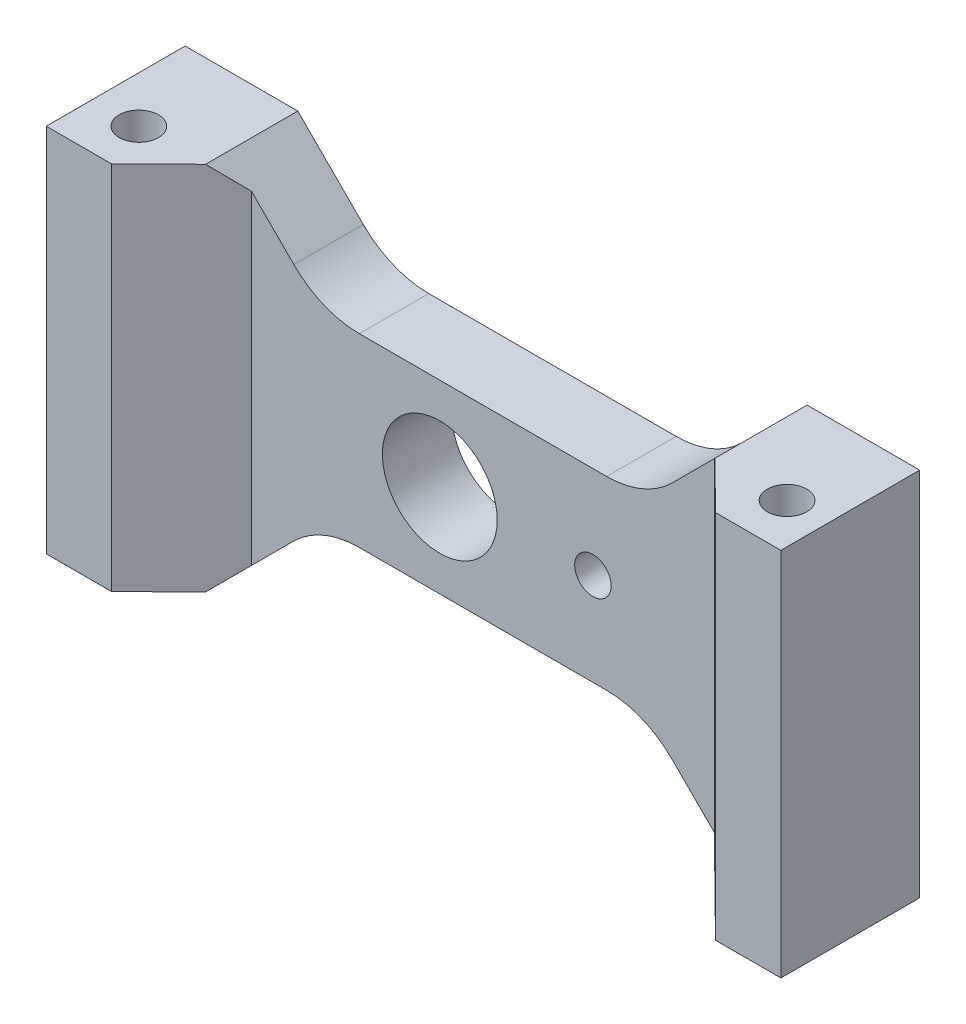
from build123d import *

# Parameters (mm, degrees)
SKETCH1_R                 = 1.35255
BOSS_EXTRUDE1_DEPTH       = 25.4
SKETCH2_R                 = 3.937
CUT_EXTRUDE1_DEPTH        = 5.7625
M3X0_5_TAPPED_HOLE1_D     = 2.5
M3X0_5_TAPPED_HOLE1_DEPTH = 4.7625
CUT_EXTRUDE2_DEPTH        = 10.525


with BuildPart() as part:
    # Sketch1 → Boss-Extrude1 (new body)
    with BuildSketch(Plane(origin=(0, 0, 0), x_dir=(1, 0, 0), z_dir=(0, 1, 0))):
        Polygon((25.187315329, 0), (-25.187315329, 0), (-25.187315329, -9.525), (-20.711502729, -9.525), (-15.875, -4.7625), (15.875, -4.7625), (20.711502729, -9.525), (25.187315329, -9.525), align=None)
        with Locations((-22.012315329, -6.35)):
            Circle(SKETCH1_R, mode=Mode.SUBTRACT)
        with Locations((22.437684671, -6.35)):
            Circle(SKETCH1_R, mode=Mode.SUBTRACT)
    extrude(amount=BOSS_EXTRUDE1_DEPTH)

    # Sketch2 → Cut-Extrude1 (cut, through all)
    with BuildSketch(Plane.XY.offset(4.7625)):
        with Locations((-2.962315329, 12.7)):
            Circle(SKETCH2_R)
    extrude(amount=-CUT_EXTRUDE1_DEPTH, mode=Mode.SUBTRACT)

    # M3x0.5 Tapped Hole1
    with Locations(Plane.XY.offset(4.7625)):
        with Locations((7.537684671, 12.7)):
            Hole(M3X0_5_TAPPED_HOLE1_D / 2, depth=M3X0_5_TAPPED_HOLE1_DEPTH)

    # Sketch6 → Cut-Extrude2 (cut, through all)
    with BuildSketch(Plane(origin=(0, 0, 0), x_dir=(-1, 0, 0), z_dir=(0, 0, -1))):
        with BuildLine():
            Line((-17.4625, 25.4), (-12.972371939, 20.909871939))
            ThreePointArc((-12.972371939, 20.909871939), (-10.912283674, 19.533364969), (-8.482243879, 19.05))
            Line((-8.482243879, 19.05), (8.482243879, 19.05))
            ThreePointArc((8.482243879, 19.05), (10.912283674, 19.533364969), (12.972371939, 20.909871939))
            Line((12.972371939, 20.909871939), (17.4625, 25.4))
            Line((17.4625, 25.4), (-17.4625, 25.4))
        make_face()
        with BuildLine():
            Line((-17.4625, 0), (-12.972371939, 4.490128061))
            ThreePointArc((-12.972371939, 4.490128061), (-10.912283674, 5.866635031), (-8.482243879, 6.35))
            Line((-8.482243879, 6.35), (8.482243879, 6.35))
            ThreePointArc((8.482243879, 6.35), (10.912283674, 5.866635031), (12.972371939, 4.490128061))
            Line((12.972371939, 4.490128061), (17.4625, 0))
            Line((17.4625, 0), (-17.4625, 0))
        make_face()
    extrude(amount=-CUT_EXTRUDE2_DEPTH, mode=Mode.SUBTRACT)


solid = part.part
